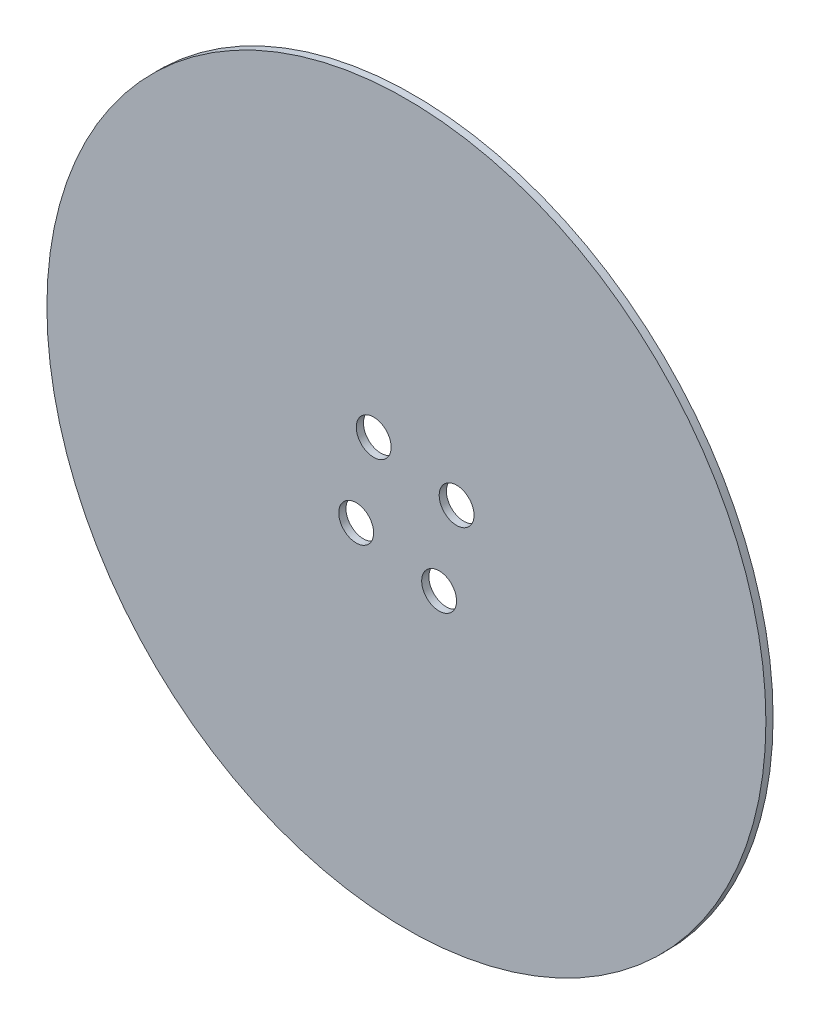
from build123d import *

# Parameters (mm, degrees)
SKETCH1_R                               = 150
BOSS_EXTRUDE2_DEPTH                     = 3
CBORE_FOR_M6_HEX_HEAD_BOLT1_D           = 6.6
CBORE_FOR_M6_HEX_HEAD_BOLT1_CBORE_D     = 14.55
CBORE_FOR_M6_HEX_HEAD_BOLT1_CBORE_DEPTH = 4.38


with BuildPart() as part:
    # Sketch1 → Boss-Extrude2 (new body)
    with BuildSketch(Plane.XY):
        Circle(SKETCH1_R)
    extrude(amount=BOSS_EXTRUDE2_DEPTH)

    # CBORE for M6 Hex Head Bolt1 (through all)
    with Locations(Plane(origin=(0, 0, 0), x_dir=(-1, 0, 0), z_dir=(0, 0, -1))):
        with Locations((-20.948618644, 13.643876902), (13.643876902, 20.948618644), (20.948618644, -13.643876902), (-13.643876902, -20.948618644)):
            CounterBoreHole(CBORE_FOR_M6_HEX_HEAD_BOLT1_D / 2, CBORE_FOR_M6_HEX_HEAD_BOLT1_CBORE_D / 2, CBORE_FOR_M6_HEX_HEAD_BOLT1_CBORE_DEPTH)


solid = part.part
